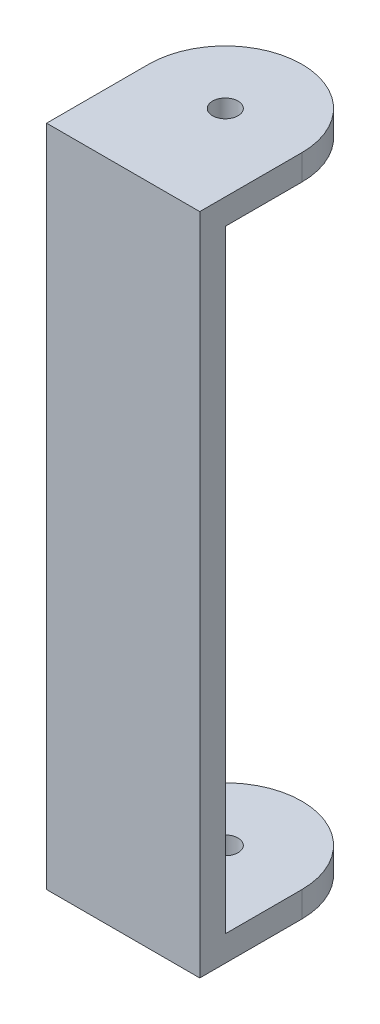
from build123d import *

# Parameters (mm, degrees)
SKETCH1_R      = 3.175
EXTRUDE1_DEPTH = 82.55
SKETCH2_W      = 38.1
SKETCH2_H      = 152.4
EXTRUDE2_DEPTH = 39.1


with BuildPart() as part:
    # Sketch1 → Extrude1 (new body, symmetric)
    with BuildSketch(Plane(origin=(0, 0, 0), x_dir=(1, 0, 0), z_dir=(0, 1, 0))):
        with BuildLine():
            Line((-19.05, -25.4), (19.05, -25.4))
            Line((19.05, -25.4), (19.05, 0))
            ThreePointArc((19.05, 0), (0, 19.05), (-19.05, 0))
            Line((-19.05, 0), (-19.05, -25.4))
        make_face()
        with Locations(Location((0, 0, 0), (0, 0, 270))):  # turned: the seam where the file's is
            Circle(SKETCH1_R, mode=Mode.SUBTRACT)
    extrude(amount=EXTRUDE1_DEPTH, both=True)

    # Sketch2 → Extrude2 (cut, through all)
    with BuildSketch(Plane(origin=(19.05, 0, 0), x_dir=(0, 0, -1), z_dir=(1, 0, 0))):
        Rectangle(SKETCH2_W, SKETCH2_H)
    extrude(amount=-EXTRUDE2_DEPTH, mode=Mode.SUBTRACT)


solid = part.part
